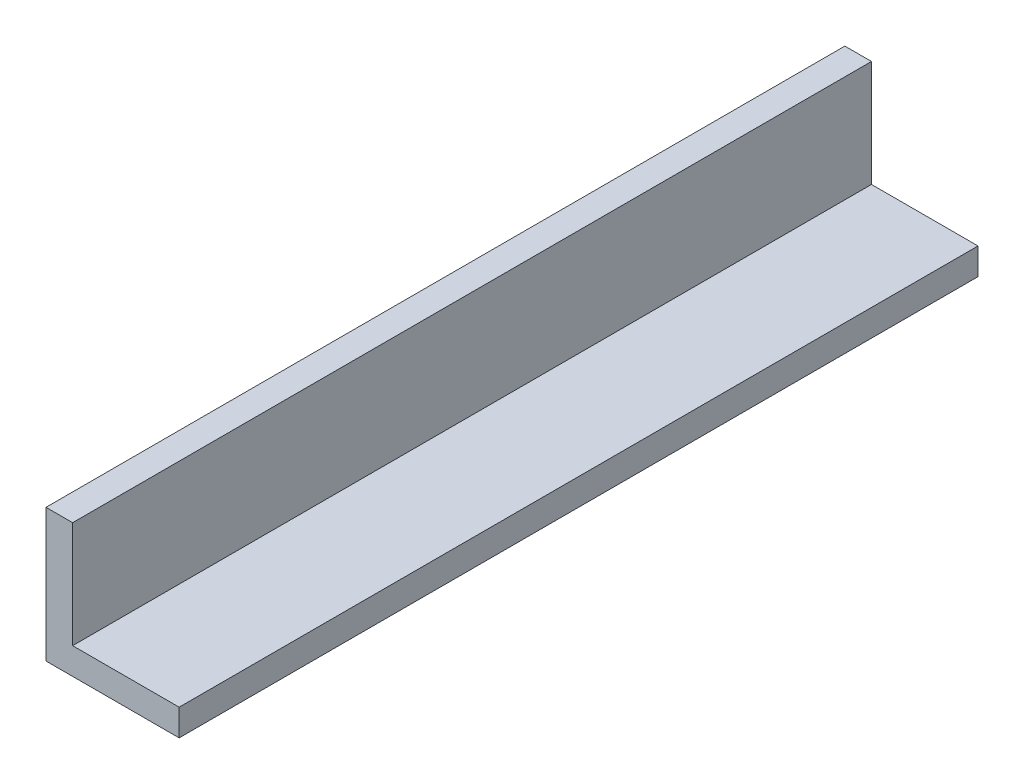
from build123d import *

# Parameters (mm, degrees)
BOSS_EXTRUDE1_DEPTH = 19.05


with BuildPart() as part:
    # Sketch1 → Boss-Extrude1 (new body, symmetric)
    with BuildSketch(Plane.XY):
        Polygon((-1.27, 5.08), (-1.27, -1.27), (5.08, -1.27), (5.08, 0), (0, 0), (0, 5.08), align=None)
    extrude(amount=BOSS_EXTRUDE1_DEPTH, both=True)


solid = part.part
